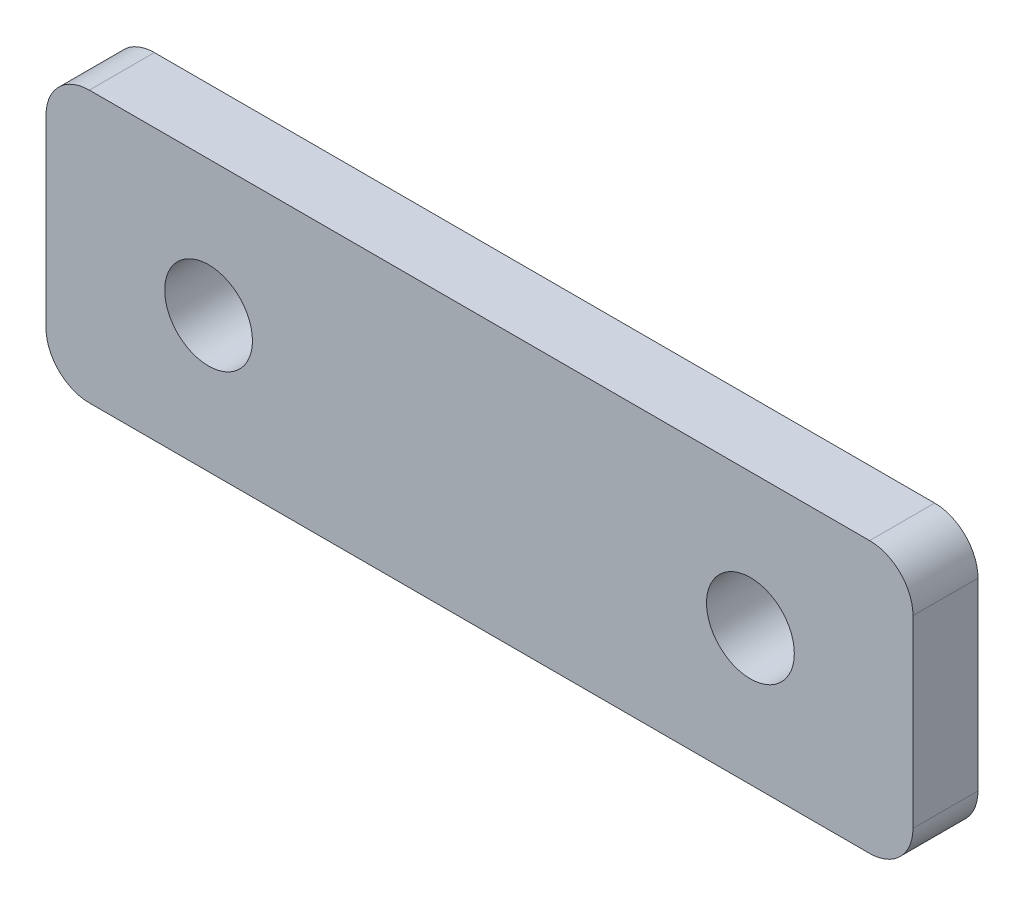
from build123d import *

# Parameters (mm, degrees)
SKETCH_1_W      = 40
SKETCH_1_H      = 12.5
SKETCH_1_R      = 2.025
EXTRUDE_1_DEPTH = 1.5
FILLET_1_R      = 2


with BuildPart() as part:
    # 草图1 → 凸台-拉伸1 (new body, symmetric)
    with BuildSketch(Plane.XY):
        Rectangle(SKETCH_1_W, SKETCH_1_H)
        with Locations((-12.5, 0)):
            Circle(SKETCH_1_R, mode=Mode.SUBTRACT)
        with Locations((12.5, 0)):
            Circle(SKETCH_1_R, mode=Mode.SUBTRACT)
    extrude(amount=EXTRUDE_1_DEPTH, both=True)

    # 圆角1
    fillet_1_edges = [part.edges().sort_by_distance(p)[0] for p in [
        (20, -6.25, 0),
        (-20, -6.25, 0),
        (-20, 6.25, 0),
        (20, 6.25, 0),
    ]]
    fillet(fillet_1_edges, radius=FILLET_1_R)


solid = part.part
